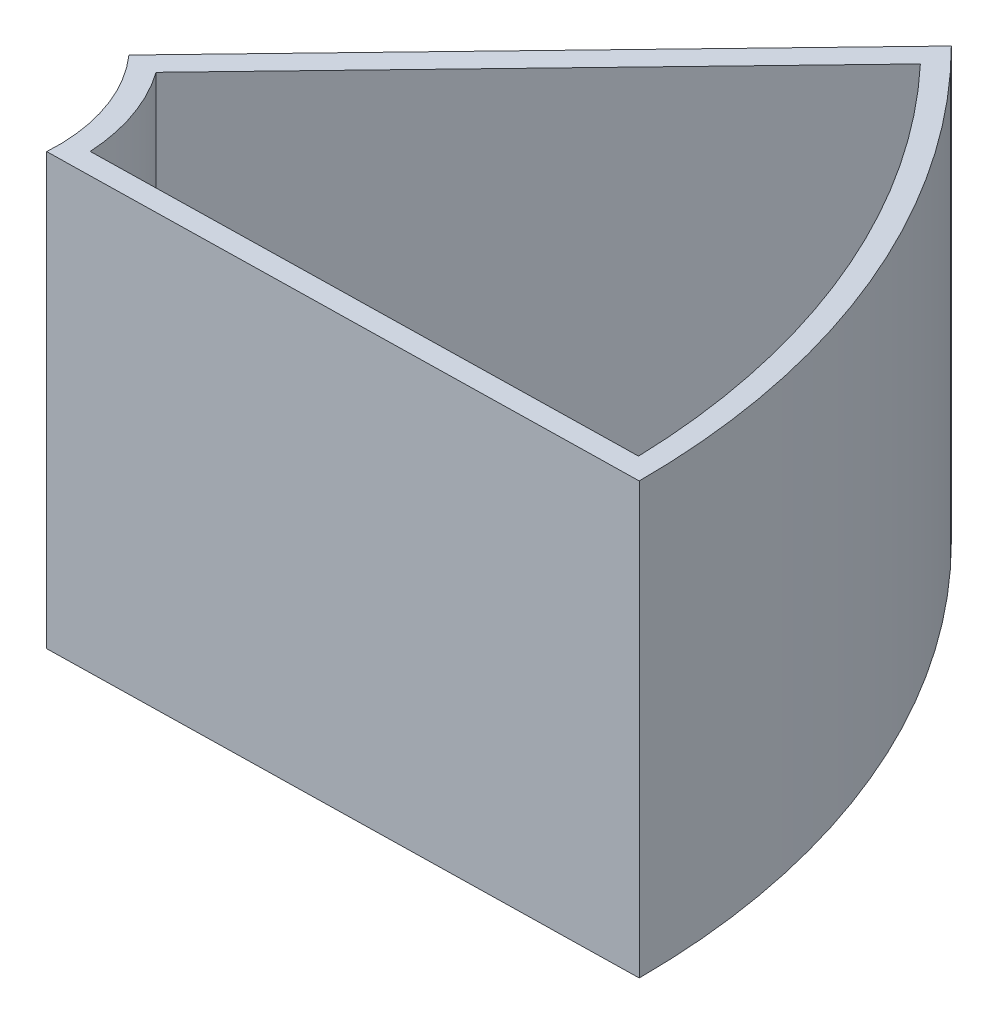
from build123d import *

# Parameters (mm, degrees)
BOSS_EXTRUDE1_DEPTH = 100
BOSS_EXTRUDE3_DEPTH = 15


with BuildPart() as part:
    # Sketch3 → Boss-Extrude1 (new body)
    with BuildSketch(Plane(origin=(0, 0, 0), x_dir=(1, 0, 0), z_dir=(0, 1, 0))):
        with BuildLine():
            Line((123.743686708, 123.743686708), (30.045678616, 26.405628121))
            ThreePointArc((30.045678616, 26.405628121), (37.863583917, 12.897635944), (39.917101801, -2.573904389))
            Line((39.917101801, -2.573904389), (175, 0))
            ThreePointArc((175, 0), (161.678918189, 66.969600664), (123.743686708, 123.743686708))
        make_face()
        with BuildLine():
            Line((36.672129032, 26.079780525), (123.758669753, 116.549524499))
            ThreePointArc((123.758669753, 116.549524499), (157.096506553, 64.966819445), (169.929243976, 4.904288086))
            Line((169.929243976, 4.904288086), (44.929243976, 2.52250584))
            ThreePointArc((44.929243976, 2.52250584), (42.466837849, 14.885149752), (36.672129032, 26.079780525))
        make_face(mode=Mode.SUBTRACT)
    extrude(amount=BOSS_EXTRUDE1_DEPTH)

    # Sketch5 → Boss-Extrude3 (add)
    with BuildSketch(Plane(origin=(0, 0, 0), x_dir=(1, 0, 0), z_dir=(0, 1, 0))):
        with BuildLine():
            Line((39.917101801, -2.573904389), (175, 0))
            ThreePointArc((175, 0), (161.678918189, 66.969600664), (123.743686708, 123.743686708))
            Line((123.743686708, 123.743686708), (30.045678616, 26.405628121))
            ThreePointArc((30.045678616, 26.405628121), (37.863583917, 12.897635944), (39.917101801, -2.573904389))
        make_face()
    extrude(amount=BOSS_EXTRUDE3_DEPTH)


solid = part.part
